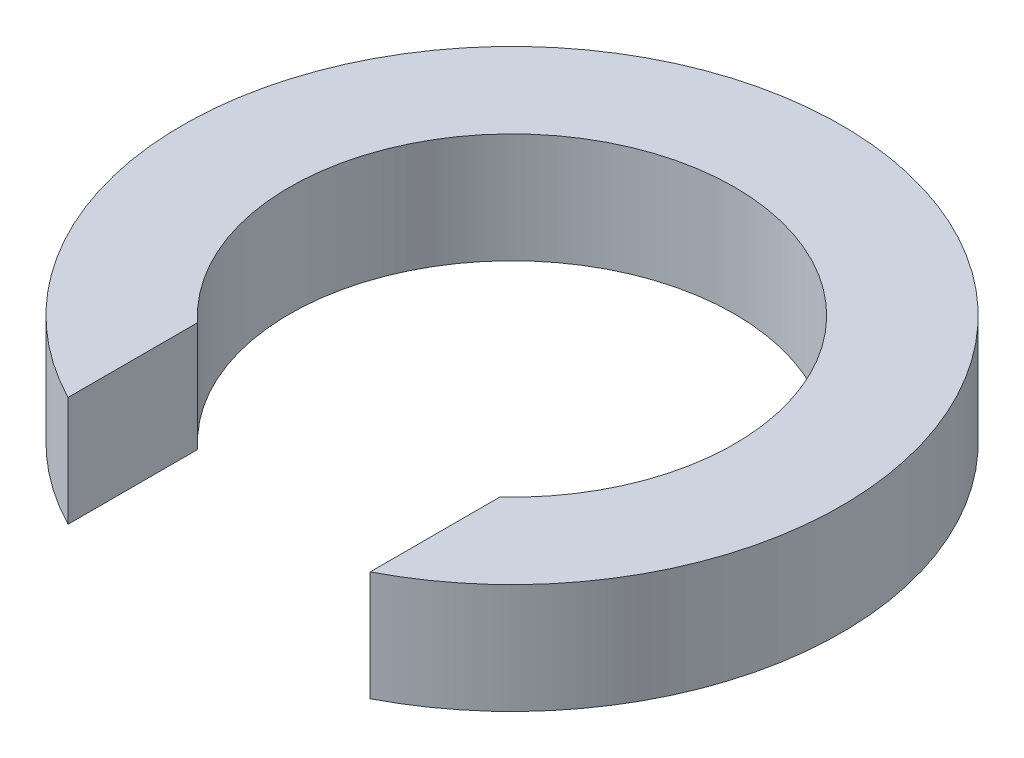
from build123d import *

# Parameters (mm, degrees)
BOSS_EXTRUDE1_DEPTH = 2


with BuildPart() as part:
    # Sketch1 → Boss-Extrude1 (new body)
    with BuildSketch(Plane(origin=(0, 0, 0), x_dir=(1, 0, 0), z_dir=(0, 1, 0))):
        with BuildLine():
            Line((-2.75, -2.973213749), (-2.75, -5.332682252))
            ThreePointArc((-2.75, -5.332682252), (0, 6), (2.75, -5.332682252))
            Line((2.75, -5.332682252), (2.75, -2.973213749))
            ThreePointArc((2.75, -2.973213749), (0, 4.05), (-2.75, -2.973213749))
        make_face()
    extrude(amount=BOSS_EXTRUDE1_DEPTH)


solid = part.part
